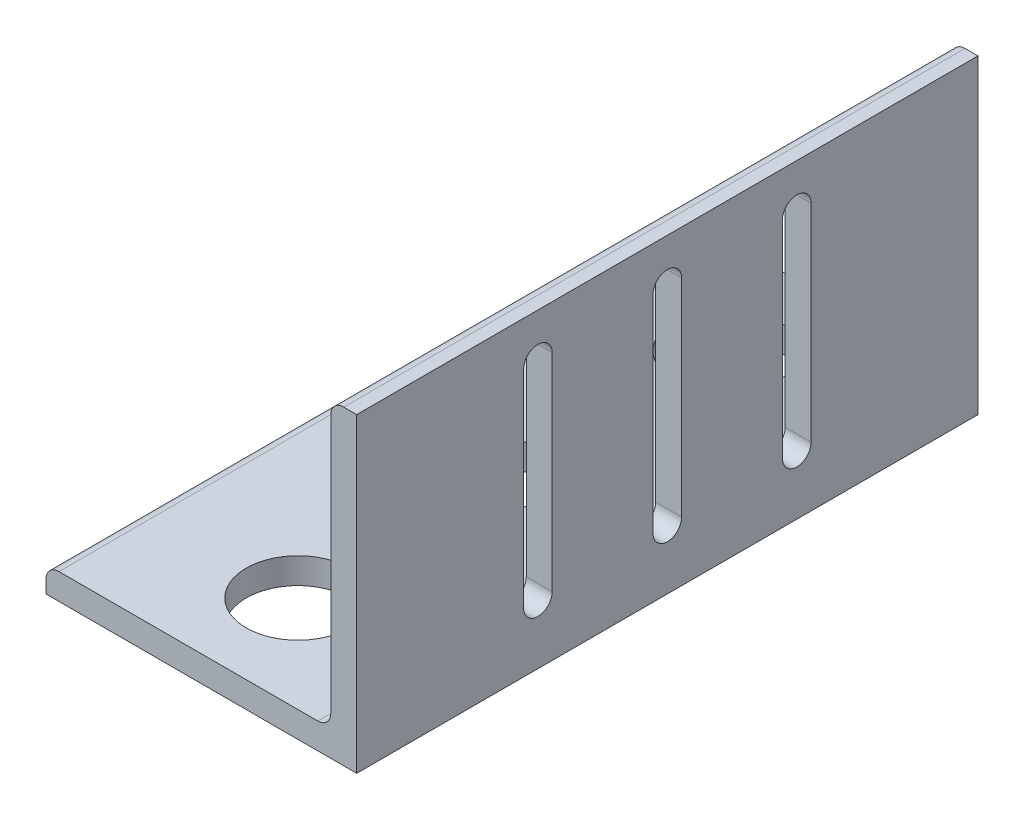
from build123d import *

# Parameters (mm, degrees)
BOSS_EXTRUDE1_DEPTH = 76.2
CUT_EXTRUDE1_DEPTH  = 10
SKETCH4_R           = 10
SKETCH4_R_2         = 12.7
CUT_EXTRUDE2_DEPTH  = 10


with BuildPart() as part:
    # Sketch2 → Boss-Extrude1 (new body, symmetric)
    with BuildSketch(Plane.XY):
        with BuildLine():
            Line((-38.1, 0), (38.1, 0))
            Line((38.1, 0), (38.1, 76.2))
            Line((38.1, 76.2), (34.925, 76.2))
            ThreePointArc((34.925, 76.2), (32.67993597, 75.27006403), (31.75, 73.025))
            Line((31.75, 73.025), (31.75, 9.525))
            ThreePointArc((31.75, 9.525), (30.82006403, 7.27993597), (28.575, 6.35))
            Line((28.575, 6.35), (-34.925, 6.35))
            ThreePointArc((-34.925, 6.35), (-37.17006403, 5.42006403), (-38.1, 3.175))
            Line((-38.1, 3.175), (-38.1, 0))
        make_face()
    extrude(amount=BOSS_EXTRUDE1_DEPTH, both=True)

    # Sketch3 → Cut-Extrude1 (cut)
    with BuildSketch(Plane(origin=(38.1, 0, 0), x_dir=(0, 0, -1), z_dir=(1, 0, 0))):
        with BuildLine():
            Line((-28.25, 65.4), (-28.25, 14.6))
            ThreePointArc((-28.25, 14.6), (-31.75, 11.1), (-35.25, 14.6))
            Line((-35.25, 14.6), (-35.25, 65.4))
            ThreePointArc((-35.25, 65.4), (-31.75, 68.9), (-28.25, 65.4))
        make_face()
        with BuildLine():
            Line((28.25, 65.4), (28.25, 14.6))
            ThreePointArc((28.25, 14.6), (31.75, 11.1), (35.25, 14.6))
            Line((35.25, 14.6), (35.25, 65.4))
            ThreePointArc((35.25, 65.4), (31.75, 68.9), (28.25, 65.4))
        make_face()
        with BuildLine():
            Line((3.5, 65.4), (3.5, 14.6))
            ThreePointArc((3.5, 14.6), (0, 11.1), (-3.5, 14.6))
            Line((-3.5, 14.6), (-3.5, 65.4))
            ThreePointArc((-3.5, 65.4), (0, 68.9), (3.5, 65.4))
        make_face()
    extrude(amount=-CUT_EXTRUDE1_DEPTH, mode=Mode.SUBTRACT)

    # Sketch4 → Cut-Extrude2 (cut)
    with BuildSketch(Plane.XZ):
        Circle(SKETCH4_R)
        with Locations((0, 52.5)):
            Circle(SKETCH4_R_2)
        with Locations((0, -52.5)):
            Circle(SKETCH4_R_2)
    extrude(amount=-CUT_EXTRUDE2_DEPTH, mode=Mode.SUBTRACT)


solid = part.part
